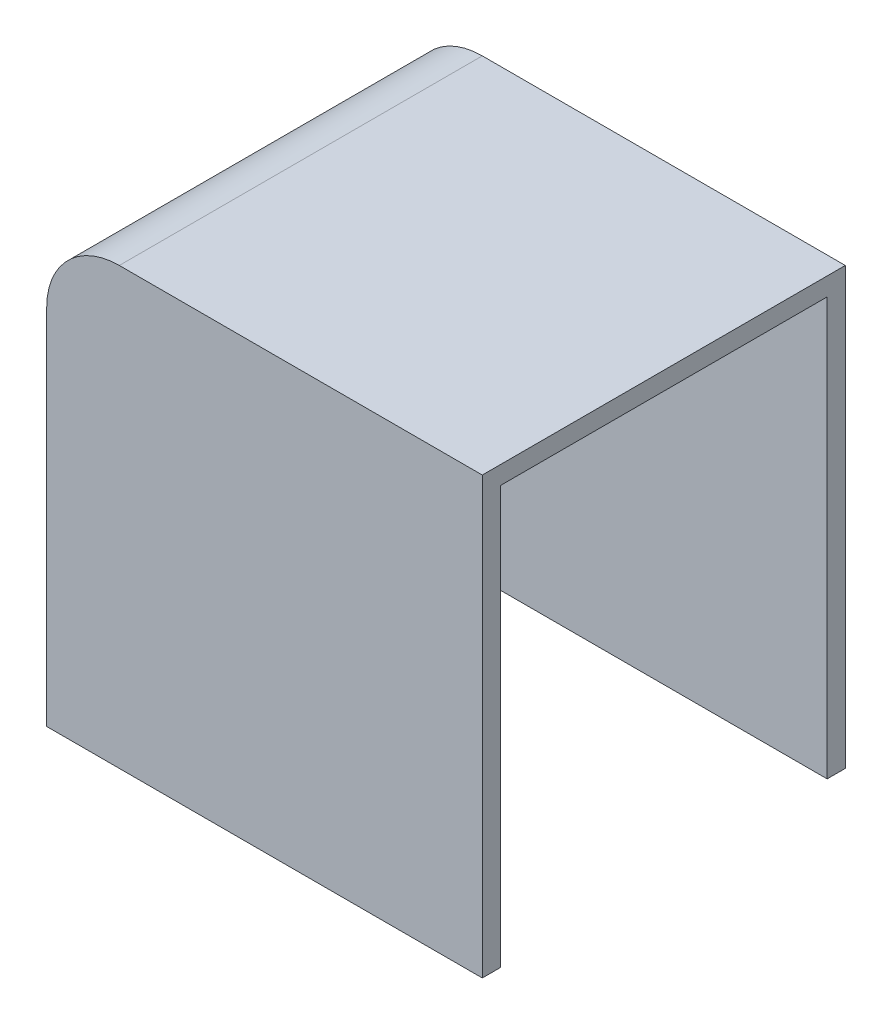
from build123d import *

# Parameters (mm, degrees)
BOSS_EXTRU_1_DEPTH = 9
BOSS_EXTRU_2_DEPTH = 0.5
BOSS_EXTRU_3_DEPTH = 0.5


with BuildPart() as part:
    # Esquisse1 → Boss.-Extru.1 (new body)
    with BuildSketch(Plane.XY):
        with BuildLine():
            Line((-12, 0), (-12, 10))
            ThreePointArc((-12, 10), (-11.414213562, 11.414213562), (-10, 12))
            Line((-10, 12), (0, 12))
            Line((0, 12), (0, 11.5))
            Line((0, 11.5), (-9.5, 11.5))
            ThreePointArc((-9.5, 11.5), (-10.914213562, 10.914213562), (-11.5, 9.5))
            Line((-11.5, 9.5), (-11.5, 0))
            Line((-11.5, 0), (-12, 0))
        make_face()
    extrude(amount=BOSS_EXTRU_1_DEPTH)

    # Esquisse2 → Boss.-Extru.2 (add)
    with BuildSketch(Plane.XY.offset(9)):
        with BuildLine():
            Line((0, 12), (0, 0))
            Line((0, 0), (-12, 0))
            Line((-12, 0), (-12, 10))
            ThreePointArc((-12, 10), (-11.414213562, 11.414213562), (-10, 12))
            Line((-10, 12), (0, 12))
        make_face()
    extrude(amount=BOSS_EXTRU_2_DEPTH)

    # Esquisse3 → Boss.-Extru.3 (add)
    with BuildSketch(Plane(origin=(0, 0, 0), x_dir=(-1, 0, 0), z_dir=(0, 0, -1))):
        with BuildLine():
            Line((0, 12), (10, 12))
            ThreePointArc((10, 12), (11.414213562, 11.414213562), (12, 10))
            Line((12, 10), (12, 0))
            Line((12, 0), (0, 0))
            Line((0, 0), (0, 12))
        make_face()
    extrude(amount=BOSS_EXTRU_3_DEPTH)


solid = part.part
